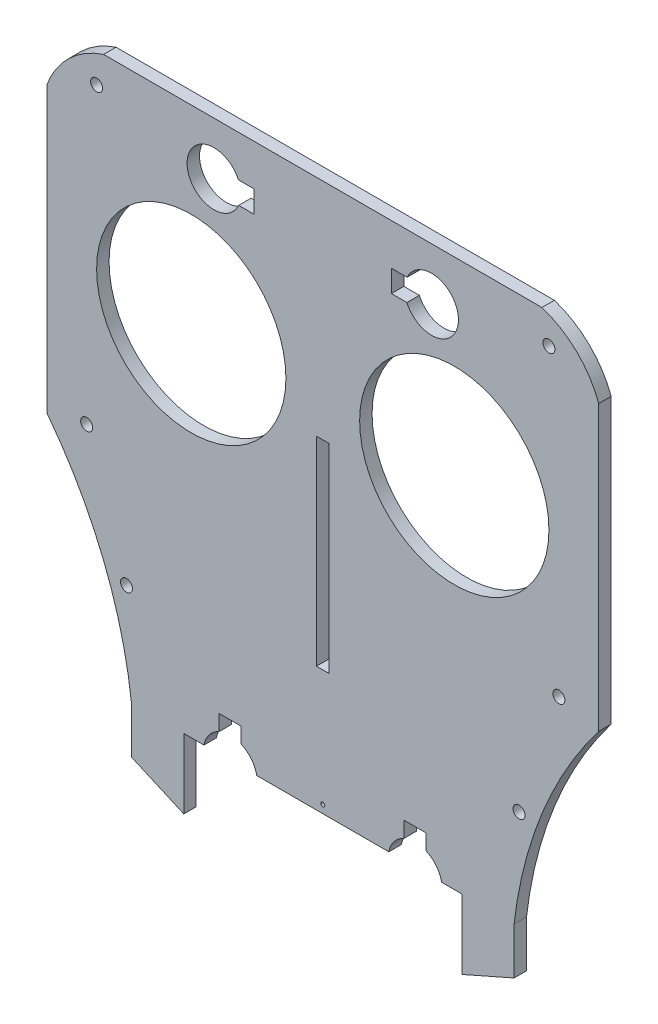
from build123d import *

# Parameters (mm, degrees)
SKETCH1_W                           = 140.716
SKETCH1_H                           = 139.7
MAIN_BODY_DEPTH                     = 3.175
SKETCH2_R                           = 24.13
CUTS_FOR_EYES_AND_MOTORS_DEPTH      = 4.175
SKETCH4_W                           = 3.2258
SKETCH4_H                           = 50.8
CUT_FOR_NOSE_DEPTH                  = 4.175
CUT_FOR_ROUNDED_FACE_FEATURES_DEPTH = 4.175
SKETCH12_R                          = 1.524
HOLES_FOR_SPACERS_DEPTH             = 4.175
BOSS_EXTRUDE1_DEPTH                 = 3.175
CUT_EXTRUDE1_DEPTH                  = 4.175
SKETCH16_R                          = 0.508
CUT_EXTRUDE2_DEPTH                  = 4.175


with BuildPart() as part:
    # Sketch1 → main body (new body)
    with BuildSketch(Plane.XY):
        with Locations((0, -69.85)):
            Rectangle(SKETCH1_W, SKETCH1_H)
    extrude(amount=MAIN_BODY_DEPTH)

    # Sketch2 → cuts for eyes and motors (cut, through all)
    with BuildSketch(Plane.XY.offset(3.175)):
        with Locations((-33.528, -48.26)):
            Circle(SKETCH2_R)
        with BuildLine():
            Line((-17.500552949, -13.319125673), (-17.500552949, -10.525125673))
            Line((-17.500552949, -10.525125673), (-21.496618579, -10.525125673))
            ThreePointArc((-21.496618579, -10.525125673), (-34.59452735, -13.425551762), (-21.451292126, -16.113125673))
            Line((-21.451292126, -16.113125673), (-17.500552949, -16.113125673))
            Line((-17.500552949, -16.113125673), (-17.500552949, -13.319125673))
        make_face()
    cuts_for_eyes_and_motors = extrude(amount=-CUTS_FOR_EYES_AND_MOTORS_DEPTH, mode=Mode.SUBTRACT)

    # Sketch4 → cut for nose (cut, through all)
    with BuildSketch(Plane.XY.offset(3.175)):
        with Locations((0, -82.55)):
            Rectangle(SKETCH4_W, SKETCH4_H)
    extrude(amount=-CUT_FOR_NOSE_DEPTH, mode=Mode.SUBTRACT)

    # Mirror1: cuts for eyes and motors across plane
    add(cuts_for_eyes_and_motors.mirror(Plane(origin=(0, 0, 0), x_dir=(0, 0, 1), z_dir=(1, 0, 0))), mode=Mode.SUBTRACT)

    # Sketch11 → cut for rounded face features (cut, through all)
    with BuildSketch(Plane.XY.offset(3.175)):
        with BuildLine():
            Line((-70.358, -139.7), (-70.358, -86.36))
            ThreePointArc((-70.358, -86.36), (-55.943359781, -111.56490753), (-48.768, -139.7))
            Line((-48.768, -139.7), (-70.358, -139.7))
        make_face()
        with BuildLine():
            Line((-70.358, 0), (-70.358, -13.97))
            ThreePointArc((-70.358, -13.97), (-64.724440046, -5.321180316), (-55.88, 0))
            Line((-55.88, 0), (-70.358, 0))
        make_face()
    cut_for_rounded_face_features = extrude(amount=-CUT_FOR_ROUNDED_FACE_FEATURES_DEPTH, mode=Mode.SUBTRACT)

    # mirror of rounded feature: cut for rounded face features across plane
    add(cut_for_rounded_face_features.mirror(Plane(origin=(0, 0, 0), x_dir=(0, 0, 1), z_dir=(1, 0, 0))), mode=Mode.SUBTRACT)

    # Sketch12 → holes for spacers (cut, through all)
    with BuildSketch(Plane.XY.offset(3.175)):
        with Locations((-57.658, -7.62)):
            Circle(SKETCH12_R)
        with Locations((-60.198, -83.82)):
            Circle(SKETCH12_R)
        with Locations((-50.038, -114.3)):
            Circle(SKETCH12_R)
    holes_for_spacers = extrude(amount=-HOLES_FOR_SPACERS_DEPTH, mode=Mode.SUBTRACT)

    # mirror of spacer hole: holes for spacers across plane
    add(holes_for_spacers.mirror(Plane(origin=(0, 0, 0), x_dir=(0, 0, 1), z_dir=(1, 0, 0))), mode=Mode.SUBTRACT)

    # Sketch14 → Boss-Extrude1 (add)
    with BuildSketch(Plane.XY.offset(3.175)):
        Polygon((-48.768, -139.7), (-35.433, -139.7), (-35.433, -157.48), (-48.768, -151.596070028), align=None)
    boss_extrude1 = extrude(amount=-BOSS_EXTRUDE1_DEPTH)

    # Mirror3: Boss-Extrude1 across plane
    add(boss_extrude1.mirror(Plane(origin=(0, 0, 0), x_dir=(0, 0, 1), z_dir=(1, 0, 0))))

    # Sketch15 → Cut-Extrude1 (cut, through all)
    with BuildSketch(Plane.XY.offset(3.175)):
        with BuildLine():
            Line((-23.622, -130.7846), (-26.416, -130.7846))
            Line((-26.416, -130.7846), (-26.416, -134.78066563))
            ThreePointArc((-26.416, -134.78066563), (-23.515573911, -147.878574401), (-20.828, -134.735339177))
            Line((-20.828, -134.735339177), (-20.828, -130.7846))
            Line((-20.828, -130.7846), (-23.622, -130.7846))
        make_face()
        with BuildLine():
            Line((23.5204, -130.7846), (20.7264, -130.7846))
            Line((20.7264, -130.7846), (20.7264, -134.78066563))
            ThreePointArc((20.7264, -134.78066563), (23.626826089, -147.878574401), (26.3144, -134.735339177))
            Line((26.3144, -134.735339177), (26.3144, -130.7846))
            Line((26.3144, -130.7846), (23.5204, -130.7846))
        make_face()
    extrude(amount=-CUT_EXTRUDE1_DEPTH, mode=Mode.SUBTRACT)

    # Sketch16 → Cut-Extrude2 (cut, through all)
    with BuildSketch(Plane.XY.offset(3.175)):
        with Locations((0, -137.668)):
            Circle(SKETCH16_R)
    extrude(amount=-CUT_EXTRUDE2_DEPTH, mode=Mode.SUBTRACT)


solid = part.part
